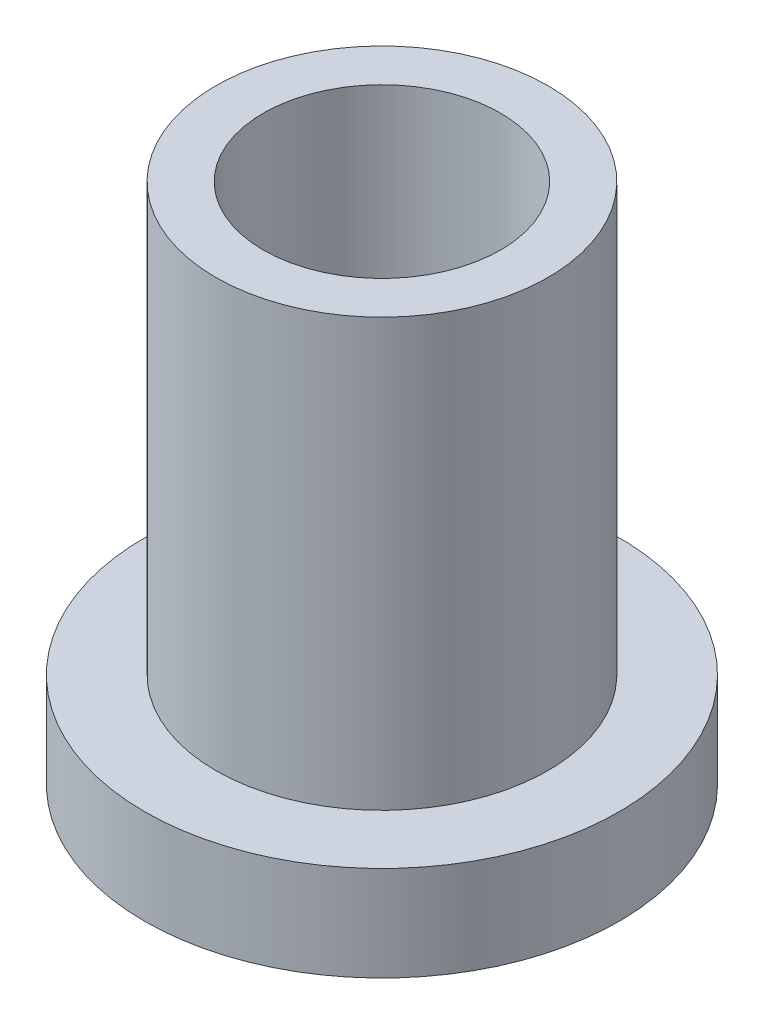
from build123d import *

# Parameters (mm, degrees)
SKETCH_1_R          = 5
EXTRUDE_1_DEPTH     = 2
SKETCH_2_R          = 3.5
EXTRUDE_2_DEPTH     = 9
SKETCH_3_R          = 2.5
CUT_EXTRUDE_1_DEPTH = 12


with BuildPart() as part:
    # Эскиз1 → Бобышка-Вытянуть1 (new body)
    with BuildSketch(Plane(origin=(0, 0, 0), x_dir=(1, 0, 0), z_dir=(0, 1, 0))):
        Circle(SKETCH_1_R)
    extrude(amount=EXTRUDE_1_DEPTH)

    # Эскиз2 → Бобышка-Вытянуть2 (add)
    with BuildSketch(Plane(origin=(0, 2, 0), x_dir=(1, 0, 0), z_dir=(0, 1, 0))):
        Circle(SKETCH_2_R)
    extrude(amount=EXTRUDE_2_DEPTH)

    # Эскиз3 → Вырез-Вытянуть1 (cut, through all)
    with BuildSketch(Plane(origin=(0, 11, 0), x_dir=(1, 0, 0), z_dir=(0, 1, 0))):
        Circle(SKETCH_3_R)
    extrude(amount=-CUT_EXTRUDE_1_DEPTH, mode=Mode.SUBTRACT)


solid = part.part
